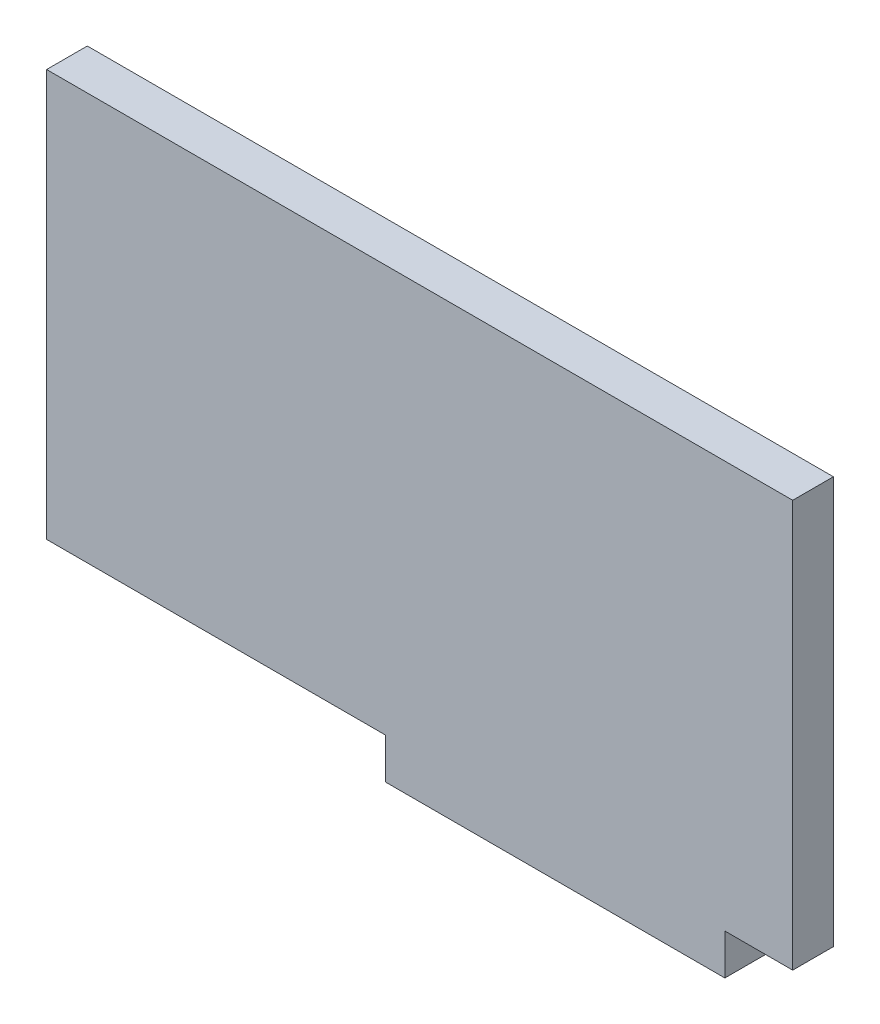
from build123d import *

# Parameters (mm, degrees)
RESSALTO_EXTRUS_O1_DEPTH = 3


with BuildPart() as part:
    # Esboço1 → Ressalto-extrusão1 (new body)
    with BuildSketch(Plane.XY):
        Polygon((-7.94118013, 1.369756817), (-2.94118013, 1.369756817), (-2.94118013, 31.369756817), (-57.94118013, 31.369756817), (-57.94118013, 1.369756817), (-32.94118013, 1.369756817), (-32.94118013, -1.630243183), (-7.94118013, -1.630243183), align=None)
    extrude(amount=RESSALTO_EXTRUS_O1_DEPTH)


solid = part.part
